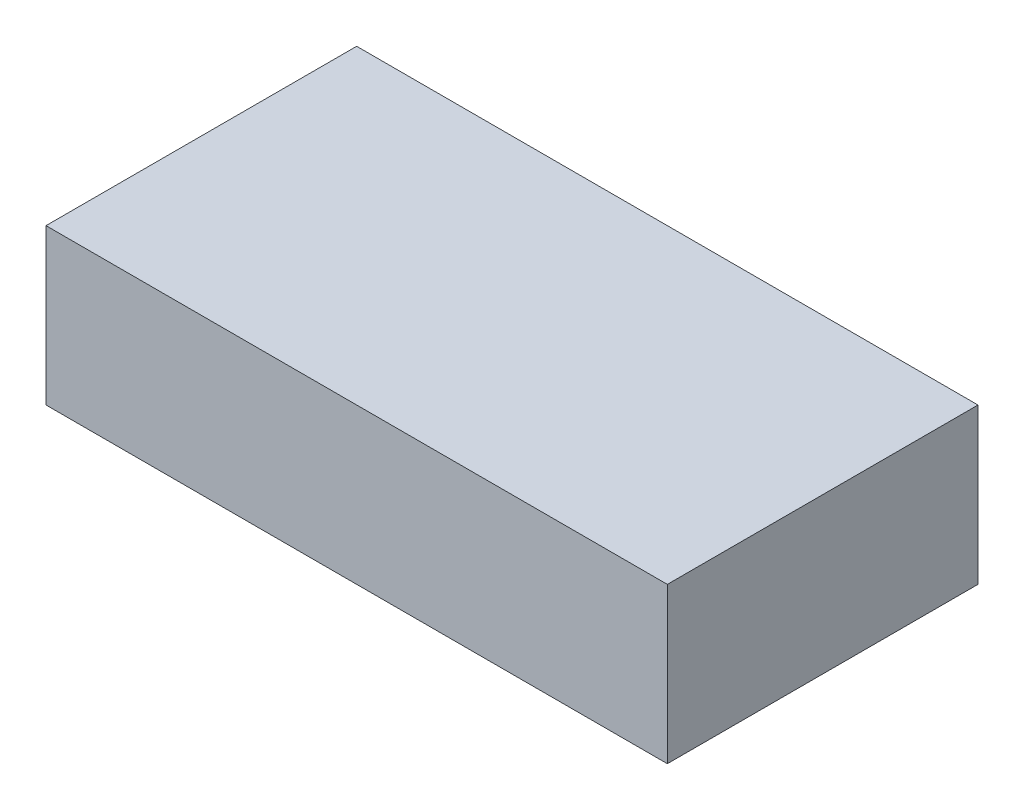
from build123d import *

# Parameters (mm, degrees)
ESQUISSE1_W        = 20
ESQUISSE1_H        = 5
BOSS_EXTRU_1_DEPTH = 10


with BuildPart() as part:
    # Esquisse1 → Boss.-Extru.1 (new body)
    with BuildSketch(Plane.XY):
        with Locations((10, -2.5)):
            Rectangle(ESQUISSE1_W, ESQUISSE1_H)
    extrude(amount=BOSS_EXTRU_1_DEPTH)


solid = part.part
